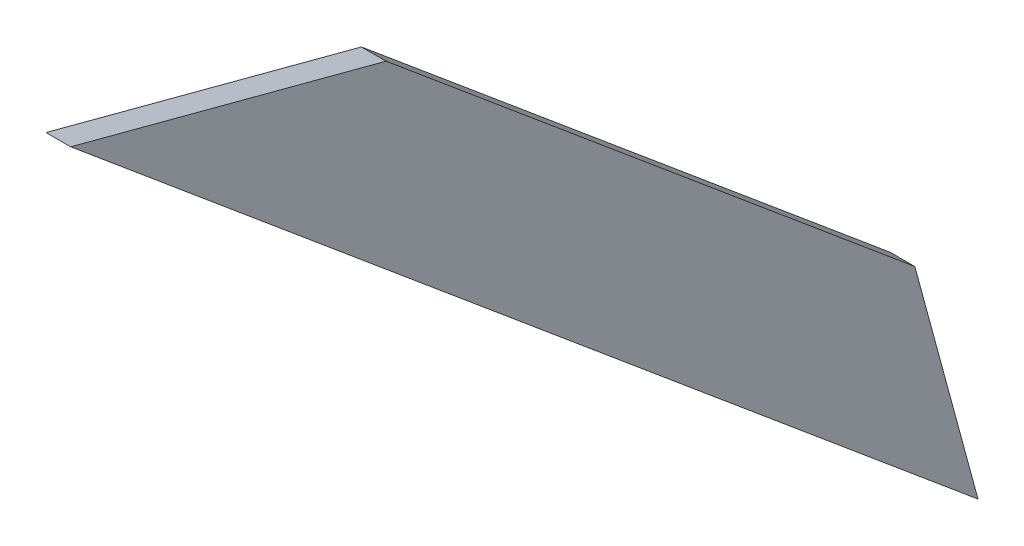
from build123d import *

# Parameters (mm, degrees)
BOSS_EXTRUDE1_DEPTH = 5


with BuildPart() as part:
    # Sketch1 → Boss-Extrude1 (new body)
    with BuildSketch(Plane(origin=(-17.662244882, 82.494913265, -223.055087324), x_dir=(0, -1, 0), z_dir=(-1, 0, 0))):
        Polygon((-168.14907428, 806.797451109), (-321.828237651, 990.574394019), (-304.906720769, 926.69067491), (-215.345197078, 819.588692669), align=None)
    extrude(amount=-BOSS_EXTRUDE1_DEPTH)


solid = part.part
